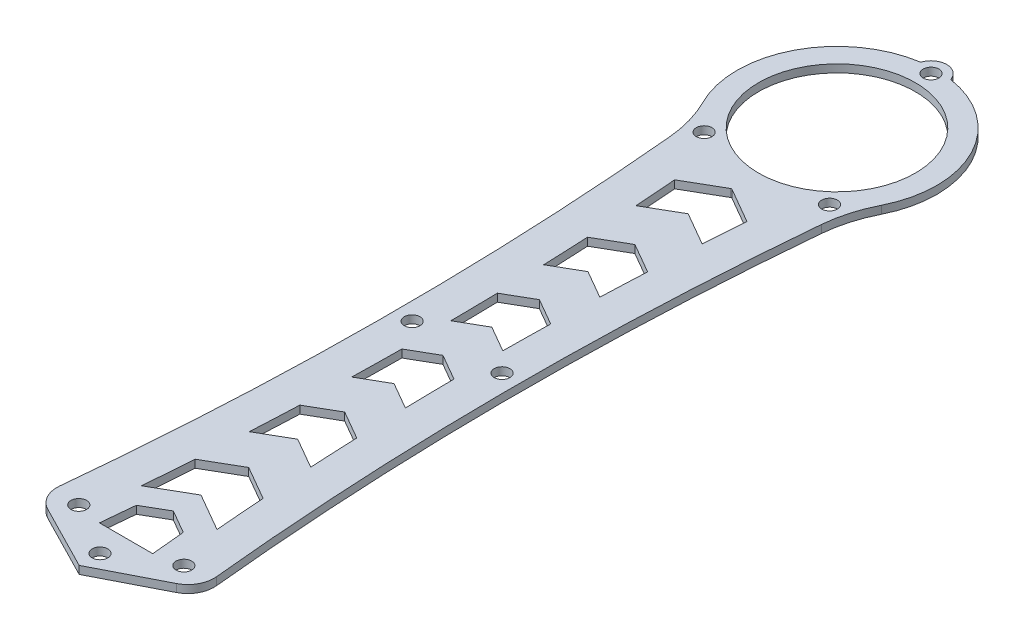
from build123d import *

# Parameters (mm, degrees)
SKETCH_1_R      = 1.5
SKETCH_1_R_2    = 15
EXTRUDE_1_DEPTH = 1.5


with BuildPart() as part:
    # 草圖1 → 填料-伸長1 (new body)
    with BuildSketch(Plane(origin=(0, 0, 0), x_dir=(1, 0, 0), z_dir=(0, 1, 0))):
        with BuildLine():
            Line((0, -3.980931511), (12.319060855, 2.328849967))
            ThreePointArc((12.319060855, 2.328849967), (14.431141465, 4.388450613), (15.014493405, 7.28025625))
            ThreePointArc((15.014493405, 7.28025625), (11.971039141, 65.394509034), (14.52184689, 123.53246884))
            ThreePointArc((14.52184689, 123.53246884), (15.377876917, 128.098069479), (17.067022361, 132.425226083))
            ThreePointArc((17.067022361, 132.425226083), (16.965589985, 149.77375384), (2.866920195, 159.883611111))
            ThreePointArc((2.866920195, 159.883611111), (0, 162), (-2.866920195, 159.883611111))
            ThreePointArc((-2.866920195, 159.883611111), (-16.965589985, 149.77375384), (-17.067022361, 132.425226083))
            ThreePointArc((-17.067022361, 132.425226083), (-15.377876917, 128.098069479), (-14.52184689, 123.53246884))
            ThreePointArc((-14.52184689, 123.53246884), (-11.971039141, 65.394509034), (-15.014493405, 7.28025625))
            ThreePointArc((-15.014493405, 7.28025625), (-14.431141465, 4.388450613), (-12.319060855, 2.328849967))
            Line((-12.319060855, 2.328849967), (0, -3.980931511))
        make_face()
        with Locations(Location((-12, 127.583592135, 0), (0, 0, 270))):
            Circle(SKETCH_1_R, mode=Mode.SUBTRACT)
        with Locations(Location((12, 127.583592135, 0), (0, 0, 270))):
            Circle(SKETCH_1_R, mode=Mode.SUBTRACT)
        with Locations(Location((8.6, 68.325395665, 0), (0, 0, 270))):
            Circle(SKETCH_1_R, mode=Mode.SUBTRACT)
        with Locations(Location((-8.6, 68.325395665, 0), (0, 0, 270))):
            Circle(SKETCH_1_R, mode=Mode.SUBTRACT)
        with Locations(Location((10.05, 6, 0), (0, 0, 270))):
            Circle(SKETCH_1_R, mode=Mode.SUBTRACT)
        with Locations(Location((-10.05, 6, 0), (0, 0, 270))):
            Circle(SKETCH_1_R, mode=Mode.SUBTRACT)
        with Locations(Location((0, 159, 0), (0, 0, 270))):
            Circle(SKETCH_1_R, mode=Mode.SUBTRACT)
        with Locations(Location((0, 0, 0), (0, 0, 270))):
            Circle(SKETCH_1_R, mode=Mode.SUBTRACT)
        with Locations(Location((0, 141, 0), (0, 0, 270))):
            Circle(SKETCH_1_R_2, mode=Mode.SUBTRACT)
        Polygon((0, 14.042409585), (-4.491071946, 11.449487988), (-5.101164168, 5.002829556), (5.101164168, 5.002829556), (4.491071946, 11.449487988), align=None, mode=Mode.SUBTRACT)
        with BuildLine():
            Line((0, 112.532142135), (-6.334048162, 108.875177723))
            ThreePointArc((-6.334048162, 108.875177723), (-6.614696141, 112.870067669), (-6.92146425, 116.863036776))
            Line((-6.92146425, 116.863036776), (-0.136378432, 120.780407899))
            ThreePointArc((-0.136378432, 120.780407899), (0, 120.816950389), (0.136378432, 120.780407899))
            Line((0.136378432, 120.780407899), (6.92146425, 116.863036776))
            ThreePointArc((6.92146425, 116.863036776), (6.614696141, 112.870067669), (6.334048162, 108.875177723))
            Line((6.334048162, 108.875177723), (0, 112.532142135))
        make_face(mode=Mode.SUBTRACT)
        with BuildLine():
            Line((0, 102.344922167), (5.753985291, 99.02285721))
            ThreePointArc((5.753985291, 99.02285721), (5.547257407, 94.643430297), (5.371890331, 90.262635518))
            Line((5.371890331, 90.262635518), (0, 93.364097846))
            Line((0, 93.364097846), (-5.371890331, 90.262635518))
            ThreePointArc((-5.371890331, 90.262635518), (-5.547257407, 94.643430297), (-5.753985291, 99.02285721))
            Line((-5.753985291, 99.02285721), (0, 102.344922167))
        make_face(mode=Mode.SUBTRACT)
        with BuildLine():
            Line((0, 84.072725452), (5.10712289, 81.124126676))
            ThreePointArc((5.10712289, 81.124126676), (5.026699976, 76.609736924), (4.97956534, 72.094876904))
            Line((4.97956534, 72.094876904), (0, 74.969830293))
            Line((0, 74.969830293), (-4.97956534, 72.094876904))
            ThreePointArc((-4.97956534, 72.094876904), (-5.026699976, 76.609736924), (-5.10712289, 81.124126676))
            Line((-5.10712289, 81.124126676), (0, 84.072725452))
        make_face(mode=Mode.SUBTRACT)
        with BuildLine():
            Line((0, 65.619773758), (4.987851065, 62.740036603))
            ThreePointArc((4.987851065, 62.740036603), (5.046332025, 58.016878131), (5.141244155, 53.29431128))
            Line((5.141244155, 53.29431128), (0, 56.262609977))
            Line((0, 56.262609977), (-5.141244155, 53.29431128))
            ThreePointArc((-5.141244155, 53.29431128), (-5.046332025, 58.016878131), (-4.987851065, 62.740036603))
            Line((-4.987851065, 62.740036603), (0, 65.619773758))
        make_face(mode=Mode.SUBTRACT)
        with BuildLine():
            Line((0, 46.827706802), (5.447027498, 43.68286401))
            ThreePointArc((5.447027498, 43.68286401), (5.648052955, 39.057684109), (5.884040018, 34.434156186))
            Line((5.884040018, 34.434156186), (0, 37.831308275))
            Line((0, 37.831308275), (-5.884040018, 34.434156186))
            ThreePointArc((-5.884040018, 34.434156186), (-5.648052955, 39.057684109), (-5.447027498, 43.68286401))
            Line((-5.447027498, 43.68286401), (0, 46.827706802))
        make_face(mode=Mode.SUBTRACT)
        with BuildLine():
            Line((0, 28.460830008), (6.494782795, 24.711065414))
            ThreePointArc((6.494782795, 24.711065414), (6.852315766, 19.927479382), (7.247310233, 15.146840877))
            Line((7.247310233, 15.146840877), (0, 19.331077391))
            Line((0, 19.331077391), (-7.247310233, 15.146840877))
            ThreePointArc((-7.247310233, 15.146840877), (-6.852315766, 19.927479382), (-6.494782795, 24.711065414))
            Line((-6.494782795, 24.711065414), (0, 28.460830008))
        make_face(mode=Mode.SUBTRACT)
    extrude(amount=EXTRUDE_1_DEPTH)


solid = part.part
